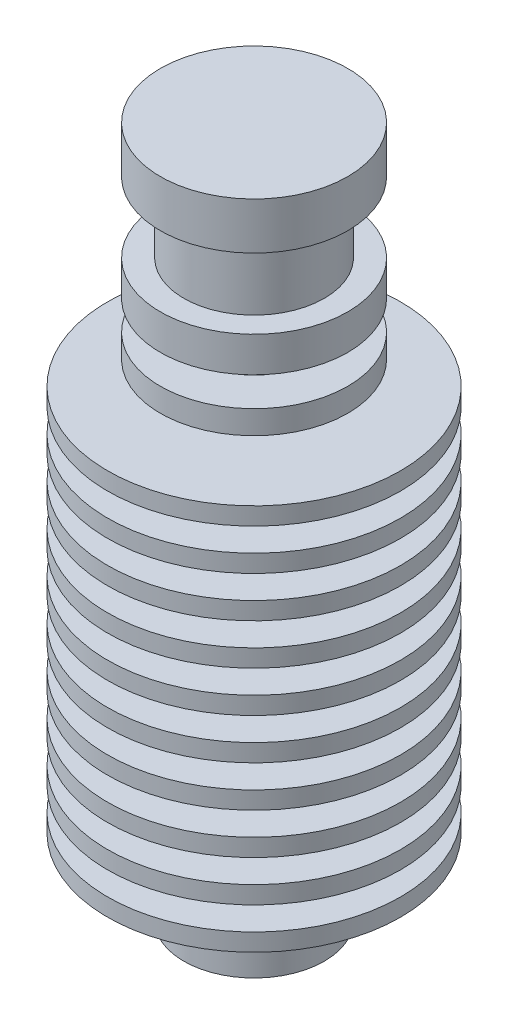
from build123d import *


with BuildPart() as part:
    # Sketch1 → Revolve1 (revolve)
    with BuildSketch(Plane.XY):
        Polygon((0, 29.5), (8, 29.5), (8, 25.5), (6, 25.5), (6, 19.5), (8, 19.5), (8, 16.5), (4.5, 16.5), (4.5, 14), (8, 14), (8, 12), (4.5, 12), (4.5, 10), (12.5, 10), (12.5, 8.5), (4.5, 8.5), (4.5, 6.5), (12.5, 6.5), (12.5, 5), (4.5, 5), (4.5, 3), (12.5, 3), (12.5, 1.5), (4.5, 1.5), (4.5, -0.5), (12.5, -0.5), (12.5, -2), (6.5, -2), (6.5, -4), (12.5, -4), (12.5, -5.5), (7.5, -5.5), (7.5, -7.5), (12.5, -7.5), (12.5, -9), (7.5, -9), (7.5, -11), (12.5, -11), (12.5, -12.5), (7.5, -12.5), (7.5, -14.5), (12.5, -14.5), (12.5, -16), (7.5, -16), (7.5, -18), (12.5, -18), (12.5, -19.5), (7.5, -19.5), (7.5, -21.5), (12.5, -21.5), (12.5, -23), (4, -23), (4, -25), (6, -25), (6, -29.5), (0, -29.5), align=None)
    revolve(axis=Axis((0, -29.5, 0), (0, 1, 0)))


solid = part.part
